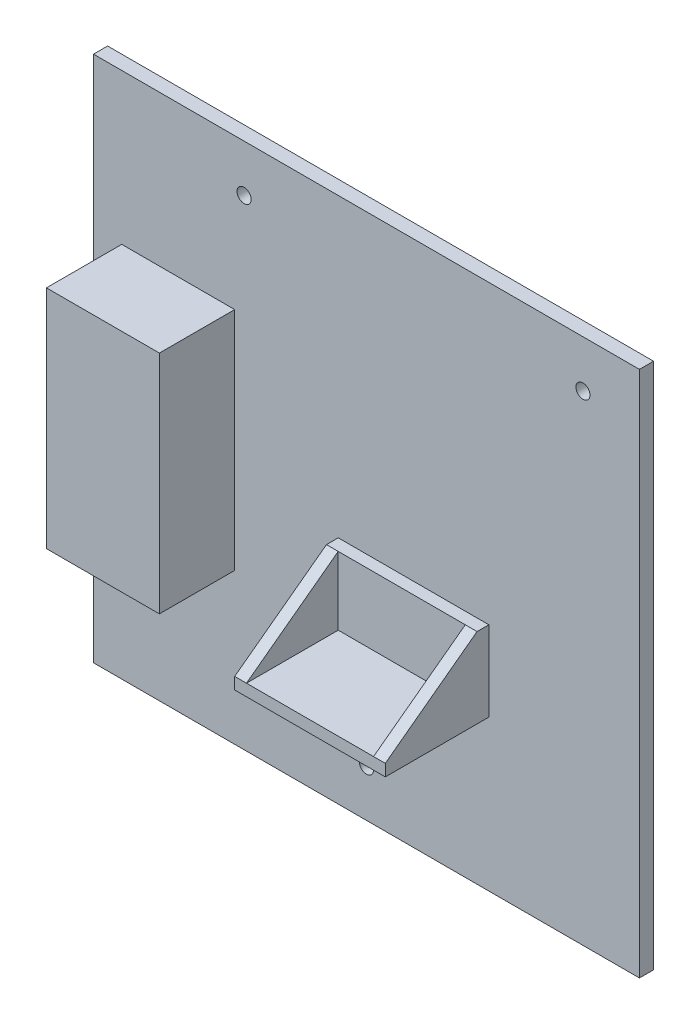
from build123d import *

# Parameters (mm, degrees)
SKETCH1_W           = 116
SKETCH1_H           = 112
BOSS_EXTRUDE1_DEPTH = 3
SKETCH2_W           = 24
SKETCH2_H           = 48
BOSS_EXTRUDE2_DEPTH = 16
SKETCH3_W           = 32
SKETCH3_H           = 17
BOSS_EXTRUDE3_DEPTH = 22
CUT_EXTRUDE1_REACH  = 86
SKETCH5_W           = 27
SKETCH5_H           = 14.5
CUT_EXTRUDE2_DEPTH  = 19.5
CUT_EXTRUDE3_REACH  = 5
SKETCH6_R           = 1.5


with BuildPart() as part:
    # Sketch1 → Boss-Extrude1 (new body)
    with BuildSketch(Plane.XY):
        Rectangle(SKETCH1_W, SKETCH1_H)
    extrude(amount=BOSS_EXTRUDE1_DEPTH)

    # Sketch2 → Boss-Extrude2 (add)
    with BuildSketch(Plane.XY.offset(3)):
        with Locations((-40, 0)):
            Rectangle(SKETCH2_W, SKETCH2_H)
    extrude(amount=BOSS_EXTRUDE2_DEPTH)

    # Sketch3 → Boss-Extrude3 (add)
    with BuildSketch(Plane.XY.offset(3)):
        with Locations((10, -15.5)):
            Rectangle(SKETCH3_W, SKETCH3_H)
    extrude(amount=BOSS_EXTRUDE3_DEPTH)

    # Sketch4 → Cut-Extrude1 (cut, up to next)
    with BuildSketch(Plane(origin=(26, 0, 0), x_dir=(0, 0, -1), z_dir=(1, 0, 0)), mode=Mode.PRIVATE) as cut_extrude1_sk1:
        Polygon((-25, -21.5), (-5.5, -7), (-25, -7), align=None)
    cut_extrude1_tool1 = extrude(cut_extrude1_sk1.sketch, amount=-CUT_EXTRUDE1_REACH, mode=Mode.PRIVATE) & part.part
    add(cut_extrude1_tool1.solids().sort_by_distance((26, -11.833333, 18.5))[0], mode=Mode.SUBTRACT)

    # Sketch5 → Cut-Extrude2 (cut)
    with BuildSketch(Plane.XY.offset(25)):
        with Locations((10, -14.25)):
            Rectangle(SKETCH5_W, SKETCH5_H)
    extrude(amount=-CUT_EXTRUDE2_DEPTH, mode=Mode.SUBTRACT)

    # Sketch6 → Cut-Extrude3 (cut, up to next)
    with BuildSketch(Plane.XY.offset(3), mode=Mode.PRIVATE) as cut_extrude3_sk1:
        with Locations((-26, 46)):
            Circle(SKETCH6_R)
    cut_extrude3_tool1 = extrude(cut_extrude3_sk1.sketch, amount=-CUT_EXTRUDE3_REACH, mode=Mode.PRIVATE) & part.part
    add(cut_extrude3_tool1.solids().sort_by_distance((-26, 46, 3))[0], mode=Mode.SUBTRACT)
    # Sketch6 → Cut-Extrude3 (cut, up to next)
    with BuildSketch(Plane.XY.offset(3), mode=Mode.PRIVATE) as cut_extrude3_sk2:
        with Locations((46, 46)):
            Circle(SKETCH6_R)
    cut_extrude3_tool2 = extrude(cut_extrude3_sk2.sketch, amount=-CUT_EXTRUDE3_REACH, mode=Mode.PRIVATE) & part.part
    add(cut_extrude3_tool2.solids().sort_by_distance((46, 46, 3))[0], mode=Mode.SUBTRACT)
    # Sketch6 → Cut-Extrude3 (cut, up to next)
    with BuildSketch(Plane.XY.offset(3), mode=Mode.PRIVATE) as cut_extrude3_sk3:
        with Locations((0, -46)):
            Circle(SKETCH6_R)
    cut_extrude3_tool3 = extrude(cut_extrude3_sk3.sketch, amount=-CUT_EXTRUDE3_REACH, mode=Mode.PRIVATE) & part.part
    add(cut_extrude3_tool3.solids().sort_by_distance((0, -46, 3))[0], mode=Mode.SUBTRACT)


solid = part.part
